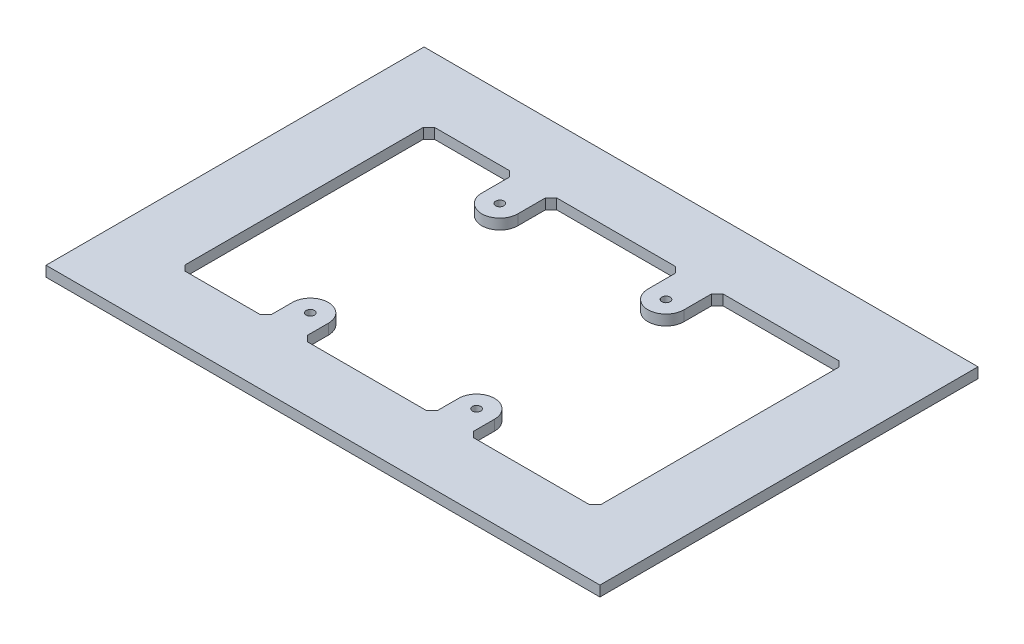
from build123d import *

# Parameters (mm, degrees)
SKETCH1_W                 = 254
SKETCH1_H                 = 173.355
BOSS_EXTRUDE1_DEPTH       = 4.7625
SKETCH2_W                 = 190.5
SKETCH2_H                 = 114.3
CUT_EXTRUDE1_DEPTH        = 4.7625
BOSS_EXTRUDE2_DEPTH       = 4.7625
F_6_CLEARANCE_HOLE1_D     = 3.7973
F_6_CLEARANCE_HOLE1_DEPTH = 25.4
F_6_CLEARANCE_HOLE1_TIP   = 1.140824014
CHAMFER1_SIZE             = 2.54


with BuildPart() as part:
    # Sketch1 → Boss-Extrude1 (new body)
    with BuildSketch(Plane(origin=(0, 0, 0), x_dir=(1, 0, 0), z_dir=(0, 1, 0))):
        with Locations((127, -86.6775)):
            Rectangle(SKETCH1_W, SKETCH1_H)
    extrude(amount=BOSS_EXTRUDE1_DEPTH)

    # Sketch2 → Cut-Extrude1 (cut)
    with BuildSketch(Plane(origin=(0, 4.7625, 0), x_dir=(1, 0, 0), z_dir=(0, 1, 0))):
        with Locations((127, -86.6775)):
            Rectangle(SKETCH2_W, SKETCH2_H)
    extrude(amount=-CUT_EXTRUDE1_DEPTH, mode=Mode.SUBTRACT)

    # Sketch3 → Boss-Extrude2 (add)
    with BuildSketch(Plane(origin=(0, 4.7625, 0), x_dir=(1, 0, 0), z_dir=(0, 1, 0))):
        with BuildLine():
            Line((163.957, -29.5275), (147.447, -29.5275))
            Line((147.447, -29.5275), (147.447, -44.7675))
            ThreePointArc((147.447, -44.7675), (155.702, -53.0225), (163.957, -44.7675))
            Line((163.957, -44.7675), (163.957, -29.5275))
        make_face()
        with BuildLine():
            Line((71.247, -29.5275), (71.247, -44.7675))
            ThreePointArc((71.247, -44.7675), (79.502, -53.0225), (87.757, -44.7675))
            Line((87.757, -44.7675), (87.757, -29.5275))
            Line((87.757, -29.5275), (71.247, -29.5275))
        make_face()
        with BuildLine():
            Line((71.247, -143.8275), (87.757, -143.8275))
            Line((87.757, -143.8275), (87.757, -131.6355))
            ThreePointArc((87.757, -131.6355), (79.502, -123.3805), (71.247, -131.6355))
            Line((71.247, -131.6355), (71.247, -143.8275))
        make_face()
        with BuildLine():
            Line((147.447, -131.6355), (147.447, -143.8275))
            Line((147.447, -143.8275), (163.957, -143.8275))
            Line((163.957, -143.8275), (163.957, -131.6355))
            ThreePointArc((163.957, -131.6355), (155.702, -123.3805), (147.447, -131.6355))
        make_face()
    extrude(amount=-BOSS_EXTRUDE2_DEPTH)

    # #6 Clearance Hole1
    with Locations(Plane(origin=(0, 4.7625, 0), x_dir=(-1, 0, 0), z_dir=(0, 1, 0))):
        with Locations((-79.502, 44.7675), (-155.702, 44.7675), (-79.502, 131.6355), (-155.702, 131.6355)):
            Hole(F_6_CLEARANCE_HOLE1_D / 2, depth=F_6_CLEARANCE_HOLE1_DEPTH)
            with Locations((0, 0, -(F_6_CLEARANCE_HOLE1_DEPTH + F_6_CLEARANCE_HOLE1_TIP / 2))):  # 118° drill point
                Cone(0, F_6_CLEARANCE_HOLE1_D / 2, F_6_CLEARANCE_HOLE1_TIP, mode=Mode.SUBTRACT)

    # Chamfer1
    chamfer1_edges = [part.edges().sort_by_distance(p)[0] for p in [
        (31.75, 2.38125, 143.8275),
        (31.75, 2.38125, 29.5275),
        (222.25, 2.38125, 29.5275),
        (222.25, 2.38125, 143.8275),
        (147.447, 2.38125, 29.5275),
        (163.957, 2.38125, 29.5275),
        (71.247, 2.38125, 29.5275),
        (87.757, 2.38125, 29.5275),
        (87.757, 2.38125, 143.8275),
        (71.247, 2.38125, 143.8275),
        (163.957, 2.38125, 143.8275),
        (147.447, 2.38125, 143.8275),
    ]]
    chamfer(chamfer1_edges, length=CHAMFER1_SIZE)


solid = part.part
